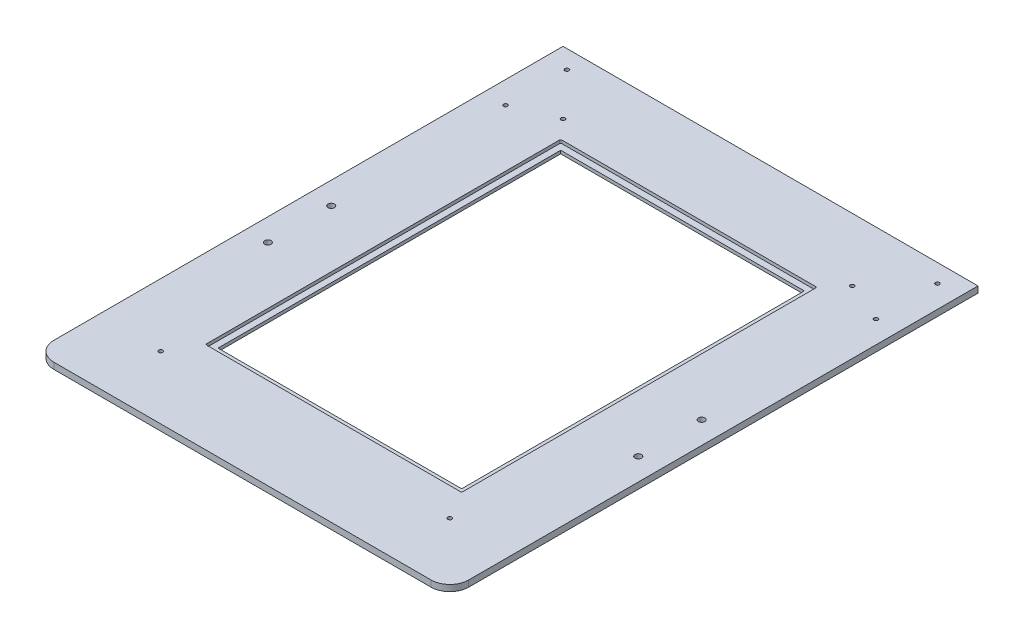
from build123d import *

# Parameters (mm, degrees)
SKETCH1_W                    = 419.1
SKETCH1_H                    = 533.4
SKETCH1_W_2                  = 246.0625
SKETCH1_H_2                  = 346.075
OVERALL_SHAPE_DEPTH          = 6.35
SKETCH5_W                    = 258.7625
SKETCH5_H                    = 358.775
GLASS_INSET_CUT_DEPTH        = 3.19999995
GLASS_INSET_FILLETS_R        = 1.27
FILLET1_R                    = 19.05
F_10_32_TAPPED_HOLE3_D       = 4.0386
F_10_32_TAPPED_HOLE3_DEPTH   = 6.35
F_10_32_TAPPED_HOLE7_D       = 4.0386
F_10_32_TAPPED_HOLE7_DEPTH   = 6.35
F_5_16_18_TAPPED_HOLE1_D     = 6.5278
F_5_16_18_TAPPED_HOLE1_DEPTH = 6.35


with BuildPart() as part:
    # Sketch1 → Overall shape (new body)
    with BuildSketch(Plane(origin=(0, 0, 0), x_dir=(1, 0, 0), z_dir=(0, 1, 0))):
        with Locations((209.55, 266.7)):
            Rectangle(SKETCH1_W, SKETCH1_H)
        with Locations((209.55, 271.4625)):
            Rectangle(SKETCH1_W_2, SKETCH1_H_2, mode=Mode.SUBTRACT)
    extrude(amount=OVERALL_SHAPE_DEPTH)

    # Sketch5 → Glass inset cut (cut)
    with BuildSketch(Plane(origin=(0, 6.35, 0), x_dir=(1, 0, 0), z_dir=(0, 1, 0))):
        with Locations((209.55, 271.4625)):
            Rectangle(SKETCH5_W, SKETCH5_H)
    extrude(amount=-GLASS_INSET_CUT_DEPTH, mode=Mode.SUBTRACT)

    # Glass inset fillets
    glass_inset_fillets_edges = [part.edges().sort_by_distance(p)[0] for p in [
        (80.16875, 4.750000025, -92.075),
        (80.16875, 4.750000025, -450.85),
        (338.93125, 4.750000025, -450.85),
        (338.93125, 4.750000025, -92.075),
    ]]
    fillet(glass_inset_fillets_edges, radius=GLASS_INSET_FILLETS_R)

    # Fillet1
    fillet1_edges = [part.edges().sort_by_distance(p)[0] for p in [
        (419.1, 3.175, 0),
        (0, 3.175, 0),
    ]]
    fillet(fillet1_edges, radius=FILLET1_R)

    # #10-32 Tapped Hole3
    with Locations(Plane(origin=(0, 6.35, 0), x_dir=(1, 0, 0), z_dir=(0, 1, 0))):
        with Locations((63.5, 469.9), (355.6, 469.9), (355.6, 63.5), (63.5, 63.5)):
            Hole(F_10_32_TAPPED_HOLE3_D / 2, depth=F_10_32_TAPPED_HOLE3_DEPTH)

    # #10-32 Tapped Hole7
    with Locations(Plane(origin=(0, 6.35, 0), x_dir=(1, 0, 0), z_dir=(0, 1, 0))):
        with Locations((22.479, 514.8707), (22.479, 452.8185), (396.621, 514.8707), (396.621, 452.8185)):
            Hole(F_10_32_TAPPED_HOLE7_D / 2, depth=F_10_32_TAPPED_HOLE7_DEPTH)

    # 5/16-18 Tapped Hole1
    with Locations(Plane(origin=(0, 6.35, 0), x_dir=(1, 0, 0), z_dir=(0, 1, 0))):
        with Locations((22.479, 276.7965), (22.479, 212.7504), (396.621, 276.7965), (396.621, 212.7504)):
            Hole(F_5_16_18_TAPPED_HOLE1_D / 2, depth=F_5_16_18_TAPPED_HOLE1_DEPTH)


solid = part.part
